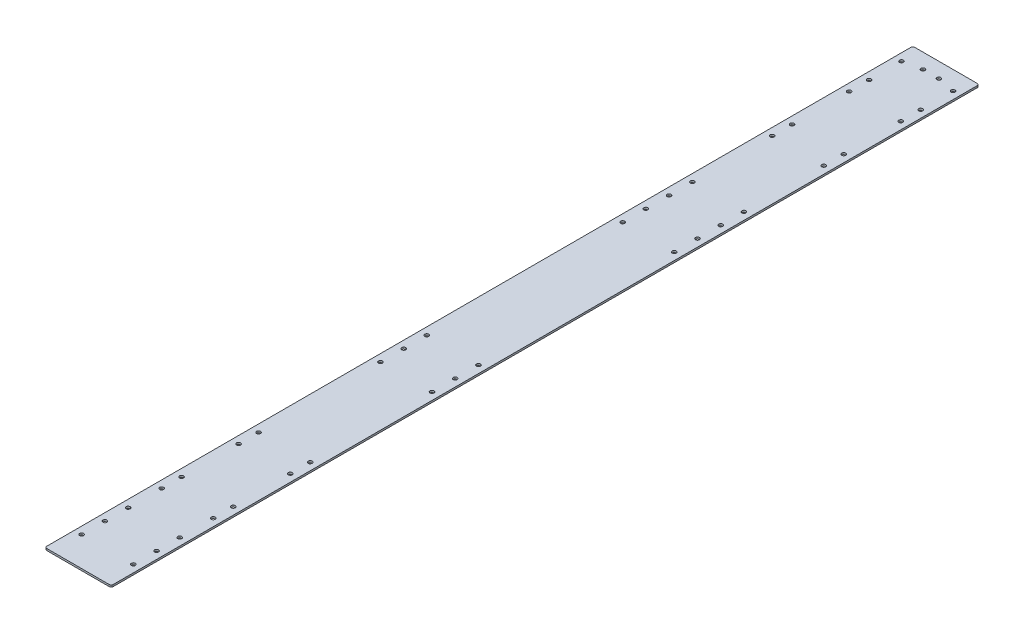
from build123d import *

# Parameters (mm, degrees)
BOSS_EXTRUDE1_DEPTH = 2.8
CUT_EXTRUDE1_REACH  = 4.8
SKETCH2_R           = 3
CUT_EXTRUDE2_REACH  = 4.8
SKETCH3_R           = 3
CUT_EXTRUDE3_REACH  = 4.8
SKETCH4_R           = 3
CUT_EXTRUDE4_REACH  = 4.8
SKETCH5_R           = 3


with BuildPart() as part:
    # Sketch1 → Boss-Extrude1 (new body)
    with BuildSketch(Plane(origin=(0, 0, 0), x_dir=(1, 0, 0), z_dir=(0, 1, 0))):
        with BuildLine():
            Line((3, 0), (97, 0))
            ThreePointArc((97, 0), (99.121320344, 0.878679656), (100, 3))
            Line((100, 3), (100, 1305))
            ThreePointArc((100, 1305), (99.121320344, 1307.121320344), (97, 1308))
            Line((97, 1308), (3, 1308))
            ThreePointArc((3, 1308), (0.878679656, 1307.121320344), (0, 1305))
            Line((0, 1305), (0, 3))
            ThreePointArc((0, 3), (0.878679656, 0.878679656), (3, 0))
        make_face()
    extrude(amount=BOSS_EXTRUDE1_DEPTH)

    # Sketch2 → Cut-Extrude1 (cut, up to next)
    with BuildSketch(Plane(origin=(0, 2.8, 0), x_dir=(1, 0, 0), z_dir=(0, 1, 0)), mode=Mode.PRIVATE) as cut_extrude1_sk1:
        with Locations((88.9, 1279.78)):
            Circle(SKETCH2_R)
    cut_extrude1_tool1 = extrude(cut_extrude1_sk1.sketch, amount=-CUT_EXTRUDE1_REACH, mode=Mode.PRIVATE) & part.part
    add(cut_extrude1_tool1.solids().sort_by_distance((88.9, 2.8, -1279.78))[0], mode=Mode.SUBTRACT)
    # Sketch2 → Cut-Extrude1 (cut, up to next)
    with BuildSketch(Plane(origin=(0, 2.8, 0), x_dir=(1, 0, 0), z_dir=(0, 1, 0)), mode=Mode.PRIVATE) as cut_extrude1_sk2:
        with Locations((88.9, 929.61)):
            Circle(SKETCH2_R)
    cut_extrude1_tool2 = extrude(cut_extrude1_sk2.sketch, amount=-CUT_EXTRUDE1_REACH, mode=Mode.PRIVATE) & part.part
    add(cut_extrude1_tool2.solids().sort_by_distance((88.9, 2.8, -929.61))[0], mode=Mode.SUBTRACT)
    # Sketch2 → Cut-Extrude1 (cut, up to next)
    with BuildSketch(Plane(origin=(0, 2.8, 0), x_dir=(1, 0, 0), z_dir=(0, 1, 0)), mode=Mode.PRIVATE) as cut_extrude1_sk3:
        with Locations((88.9, 529.56)):
            Circle(SKETCH2_R)
    cut_extrude1_tool3 = extrude(cut_extrude1_sk3.sketch, amount=-CUT_EXTRUDE1_REACH, mode=Mode.PRIVATE) & part.part
    add(cut_extrude1_tool3.solids().sort_by_distance((88.9, 2.8, -529.56))[0], mode=Mode.SUBTRACT)
    # Sketch2 → Cut-Extrude1 (cut, up to next)
    with BuildSketch(Plane(origin=(0, 2.8, 0), x_dir=(1, 0, 0), z_dir=(0, 1, 0)), mode=Mode.PRIVATE) as cut_extrude1_sk4:
        with Locations((88.9, 79.44)):
            Circle(SKETCH2_R)
    cut_extrude1_tool4 = extrude(cut_extrude1_sk4.sketch, amount=-CUT_EXTRUDE1_REACH, mode=Mode.PRIVATE) & part.part
    add(cut_extrude1_tool4.solids().sort_by_distance((88.9, 2.8, -79.44))[0], mode=Mode.SUBTRACT)
    # Sketch2 → Cut-Extrude1 (cut, up to next)
    with BuildSketch(Plane(origin=(0, 2.8, 0), x_dir=(1, 0, 0), z_dir=(0, 1, 0)), mode=Mode.PRIVATE) as cut_extrude1_sk5:
        with Locations((11.1, 79.44)):
            Circle(SKETCH2_R)
    cut_extrude1_tool5 = extrude(cut_extrude1_sk5.sketch, amount=-CUT_EXTRUDE1_REACH, mode=Mode.PRIVATE) & part.part
    add(cut_extrude1_tool5.solids().sort_by_distance((11.1, 2.8, -79.44))[0], mode=Mode.SUBTRACT)
    # Sketch2 → Cut-Extrude1 (cut, up to next)
    with BuildSketch(Plane(origin=(0, 2.8, 0), x_dir=(1, 0, 0), z_dir=(0, 1, 0)), mode=Mode.PRIVATE) as cut_extrude1_sk6:
        with Locations((11.1, 529.56)):
            Circle(SKETCH2_R)
    cut_extrude1_tool6 = extrude(cut_extrude1_sk6.sketch, amount=-CUT_EXTRUDE1_REACH, mode=Mode.PRIVATE) & part.part
    add(cut_extrude1_tool6.solids().sort_by_distance((11.1, 2.8, -529.56))[0], mode=Mode.SUBTRACT)
    # Sketch2 → Cut-Extrude1 (cut, up to next)
    with BuildSketch(Plane(origin=(0, 2.8, 0), x_dir=(1, 0, 0), z_dir=(0, 1, 0)), mode=Mode.PRIVATE) as cut_extrude1_sk7:
        with Locations((11.1, 929.61)):
            Circle(SKETCH2_R)
    cut_extrude1_tool7 = extrude(cut_extrude1_sk7.sketch, amount=-CUT_EXTRUDE1_REACH, mode=Mode.PRIVATE) & part.part
    add(cut_extrude1_tool7.solids().sort_by_distance((11.1, 2.8, -929.61))[0], mode=Mode.SUBTRACT)
    # Sketch2 → Cut-Extrude1 (cut, up to next)
    with BuildSketch(Plane(origin=(0, 2.8, 0), x_dir=(1, 0, 0), z_dir=(0, 1, 0)), mode=Mode.PRIVATE) as cut_extrude1_sk8:
        with Locations((11.1, 1279.78)):
            Circle(SKETCH2_R)
    cut_extrude1_tool8 = extrude(cut_extrude1_sk8.sketch, amount=-CUT_EXTRUDE1_REACH, mode=Mode.PRIVATE) & part.part
    add(cut_extrude1_tool8.solids().sort_by_distance((11.1, 2.8, -1279.78))[0], mode=Mode.SUBTRACT)

    # Sketch3 → Cut-Extrude2 (cut, up to next)
    with BuildSketch(Plane(origin=(0, 2.8, 0), x_dir=(1, 0, 0), z_dir=(0, 1, 0)), mode=Mode.PRIVATE) as cut_extrude2_sk1:
        with Locations((88.9, 1201)):
            Circle(SKETCH3_R)
    cut_extrude2_tool1 = extrude(cut_extrude2_sk1.sketch, amount=-CUT_EXTRUDE2_REACH, mode=Mode.PRIVATE) & part.part
    add(cut_extrude2_tool1.solids().sort_by_distance((88.9, 2.8, -1201))[0], mode=Mode.SUBTRACT)
    # Sketch3 → Cut-Extrude2 (cut, up to next)
    with BuildSketch(Plane(origin=(0, 2.8, 0), x_dir=(1, 0, 0), z_dir=(0, 1, 0)), mode=Mode.PRIVATE) as cut_extrude2_sk2:
        with Locations((88.9, 1115)):
            Circle(SKETCH3_R)
    cut_extrude2_tool2 = extrude(cut_extrude2_sk2.sketch, amount=-CUT_EXTRUDE2_REACH, mode=Mode.PRIVATE) & part.part
    add(cut_extrude2_tool2.solids().sort_by_distance((88.9, 2.8, -1115))[0], mode=Mode.SUBTRACT)
    # Sketch3 → Cut-Extrude2 (cut, up to next)
    with BuildSketch(Plane(origin=(0, 2.8, 0), x_dir=(1, 0, 0), z_dir=(0, 1, 0)), mode=Mode.PRIVATE) as cut_extrude2_sk3:
        with Locations((11.1, 1115)):
            Circle(SKETCH3_R)
    cut_extrude2_tool3 = extrude(cut_extrude2_sk3.sketch, amount=-CUT_EXTRUDE2_REACH, mode=Mode.PRIVATE) & part.part
    add(cut_extrude2_tool3.solids().sort_by_distance((11.1, 2.8, -1115))[0], mode=Mode.SUBTRACT)
    # Sketch3 → Cut-Extrude2 (cut, up to next)
    with BuildSketch(Plane(origin=(0, 2.8, 0), x_dir=(1, 0, 0), z_dir=(0, 1, 0)), mode=Mode.PRIVATE) as cut_extrude2_sk4:
        with Locations((11.1, 1201)):
            Circle(SKETCH3_R)
    cut_extrude2_tool4 = extrude(cut_extrude2_sk4.sketch, amount=-CUT_EXTRUDE2_REACH, mode=Mode.PRIVATE) & part.part
    add(cut_extrude2_tool4.solids().sort_by_distance((11.1, 2.8, -1201))[0], mode=Mode.SUBTRACT)
    # Sketch3 → Cut-Extrude2 (cut, up to next)
    with BuildSketch(Plane(origin=(0, 2.8, 0), x_dir=(1, 0, 0), z_dir=(0, 1, 0)), mode=Mode.PRIVATE) as cut_extrude2_sk5:
        with Locations((88.9, 281)):
            Circle(SKETCH3_R)
    cut_extrude2_tool5 = extrude(cut_extrude2_sk5.sketch, amount=-CUT_EXTRUDE2_REACH, mode=Mode.PRIVATE) & part.part
    add(cut_extrude2_tool5.solids().sort_by_distance((88.9, 2.8, -281))[0], mode=Mode.SUBTRACT)
    # Sketch3 → Cut-Extrude2 (cut, up to next)
    with BuildSketch(Plane(origin=(0, 2.8, 0), x_dir=(1, 0, 0), z_dir=(0, 1, 0)), mode=Mode.PRIVATE) as cut_extrude2_sk6:
        with Locations((88.9, 195)):
            Circle(SKETCH3_R)
    cut_extrude2_tool6 = extrude(cut_extrude2_sk6.sketch, amount=-CUT_EXTRUDE2_REACH, mode=Mode.PRIVATE) & part.part
    add(cut_extrude2_tool6.solids().sort_by_distance((88.9, 2.8, -195))[0], mode=Mode.SUBTRACT)
    # Sketch3 → Cut-Extrude2 (cut, up to next)
    with BuildSketch(Plane(origin=(0, 2.8, 0), x_dir=(1, 0, 0), z_dir=(0, 1, 0)), mode=Mode.PRIVATE) as cut_extrude2_sk7:
        with Locations((11.1, 195)):
            Circle(SKETCH3_R)
    cut_extrude2_tool7 = extrude(cut_extrude2_sk7.sketch, amount=-CUT_EXTRUDE2_REACH, mode=Mode.PRIVATE) & part.part
    add(cut_extrude2_tool7.solids().sort_by_distance((11.1, 2.8, -195))[0], mode=Mode.SUBTRACT)
    # Sketch3 → Cut-Extrude2 (cut, up to next)
    with BuildSketch(Plane(origin=(0, 2.8, 0), x_dir=(1, 0, 0), z_dir=(0, 1, 0)), mode=Mode.PRIVATE) as cut_extrude2_sk8:
        with Locations((11.1, 281)):
            Circle(SKETCH3_R)
    cut_extrude2_tool8 = extrude(cut_extrude2_sk8.sketch, amount=-CUT_EXTRUDE2_REACH, mode=Mode.PRIVATE) & part.part
    add(cut_extrude2_tool8.solids().sort_by_distance((11.1, 2.8, -281))[0], mode=Mode.SUBTRACT)

    # Sketch4 → Cut-Extrude3 (cut, up to next)
    with BuildSketch(Plane(origin=(0, 2.8, 0), x_dir=(1, 0, 0), z_dir=(0, 1, 0)), mode=Mode.PRIVATE) as cut_extrude3_sk1:
        with Locations((88.9, 1231)):
            Circle(SKETCH4_R)
    cut_extrude3_tool1 = extrude(cut_extrude3_sk1.sketch, amount=-CUT_EXTRUDE3_REACH, mode=Mode.PRIVATE) & part.part
    add(cut_extrude3_tool1.solids().sort_by_distance((88.9, 2.8, -1231))[0], mode=Mode.SUBTRACT)
    # Sketch4 → Cut-Extrude3 (cut, up to next)
    with BuildSketch(Plane(origin=(0, 2.8, 0), x_dir=(1, 0, 0), z_dir=(0, 1, 0)), mode=Mode.PRIVATE) as cut_extrude3_sk2:
        with Locations((88.9, 1085)):
            Circle(SKETCH4_R)
    cut_extrude3_tool2 = extrude(cut_extrude3_sk2.sketch, amount=-CUT_EXTRUDE3_REACH, mode=Mode.PRIVATE) & part.part
    add(cut_extrude3_tool2.solids().sort_by_distance((88.9, 2.8, -1085))[0], mode=Mode.SUBTRACT)
    # Sketch4 → Cut-Extrude3 (cut, up to next)
    with BuildSketch(Plane(origin=(0, 2.8, 0), x_dir=(1, 0, 0), z_dir=(0, 1, 0)), mode=Mode.PRIVATE) as cut_extrude3_sk3:
        with Locations((88.9, 964.61)):
            Circle(SKETCH4_R)
    cut_extrude3_tool3 = extrude(cut_extrude3_sk3.sketch, amount=-CUT_EXTRUDE3_REACH, mode=Mode.PRIVATE) & part.part
    add(cut_extrude3_tool3.solids().sort_by_distance((88.9, 2.8, -964.61))[0], mode=Mode.SUBTRACT)
    # Sketch4 → Cut-Extrude3 (cut, up to next)
    with BuildSketch(Plane(origin=(0, 2.8, 0), x_dir=(1, 0, 0), z_dir=(0, 1, 0)), mode=Mode.PRIVATE) as cut_extrude3_sk4:
        with Locations((88.9, 894.61)):
            Circle(SKETCH4_R)
    cut_extrude3_tool4 = extrude(cut_extrude3_sk4.sketch, amount=-CUT_EXTRUDE3_REACH, mode=Mode.PRIVATE) & part.part
    add(cut_extrude3_tool4.solids().sort_by_distance((88.9, 2.8, -894.61))[0], mode=Mode.SUBTRACT)
    # Sketch4 → Cut-Extrude3 (cut, up to next)
    with BuildSketch(Plane(origin=(0, 2.8, 0), x_dir=(1, 0, 0), z_dir=(0, 1, 0)), mode=Mode.PRIVATE) as cut_extrude3_sk5:
        with Locations((88.9, 564.56)):
            Circle(SKETCH4_R)
    cut_extrude3_tool5 = extrude(cut_extrude3_sk5.sketch, amount=-CUT_EXTRUDE3_REACH, mode=Mode.PRIVATE) & part.part
    add(cut_extrude3_tool5.solids().sort_by_distance((88.9, 2.8, -564.56))[0], mode=Mode.SUBTRACT)
    # Sketch4 → Cut-Extrude3 (cut, up to next)
    with BuildSketch(Plane(origin=(0, 2.8, 0), x_dir=(1, 0, 0), z_dir=(0, 1, 0)), mode=Mode.PRIVATE) as cut_extrude3_sk6:
        with Locations((88.9, 494.56)):
            Circle(SKETCH4_R)
    cut_extrude3_tool6 = extrude(cut_extrude3_sk6.sketch, amount=-CUT_EXTRUDE3_REACH, mode=Mode.PRIVATE) & part.part
    add(cut_extrude3_tool6.solids().sort_by_distance((88.9, 2.8, -494.56))[0], mode=Mode.SUBTRACT)
    # Sketch4 → Cut-Extrude3 (cut, up to next)
    with BuildSketch(Plane(origin=(0, 2.8, 0), x_dir=(1, 0, 0), z_dir=(0, 1, 0)), mode=Mode.PRIVATE) as cut_extrude3_sk7:
        with Locations((88.9, 114.44)):
            Circle(SKETCH4_R)
    cut_extrude3_tool7 = extrude(cut_extrude3_sk7.sketch, amount=-CUT_EXTRUDE3_REACH, mode=Mode.PRIVATE) & part.part
    add(cut_extrude3_tool7.solids().sort_by_distance((88.9, 2.8, -114.44))[0], mode=Mode.SUBTRACT)
    # Sketch4 → Cut-Extrude3 (cut, up to next)
    with BuildSketch(Plane(origin=(0, 2.8, 0), x_dir=(1, 0, 0), z_dir=(0, 1, 0)), mode=Mode.PRIVATE) as cut_extrude3_sk8:
        with Locations((88.9, 44.44)):
            Circle(SKETCH4_R)
    cut_extrude3_tool8 = extrude(cut_extrude3_sk8.sketch, amount=-CUT_EXTRUDE3_REACH, mode=Mode.PRIVATE) & part.part
    add(cut_extrude3_tool8.solids().sort_by_distance((88.9, 2.8, -44.44))[0], mode=Mode.SUBTRACT)
    # Sketch4 → Cut-Extrude3 (cut, up to next)
    with BuildSketch(Plane(origin=(0, 2.8, 0), x_dir=(1, 0, 0), z_dir=(0, 1, 0)), mode=Mode.PRIVATE) as cut_extrude3_sk9:
        with Locations((88.9, 311)):
            Circle(SKETCH4_R)
    cut_extrude3_tool9 = extrude(cut_extrude3_sk9.sketch, amount=-CUT_EXTRUDE3_REACH, mode=Mode.PRIVATE) & part.part
    add(cut_extrude3_tool9.solids().sort_by_distance((88.9, 2.8, -311))[0], mode=Mode.SUBTRACT)
    # Sketch4 → Cut-Extrude3 (cut, up to next)
    with BuildSketch(Plane(origin=(0, 2.8, 0), x_dir=(1, 0, 0), z_dir=(0, 1, 0)), mode=Mode.PRIVATE) as cut_extrude3_sk10:
        with Locations((88.9, 165)):
            Circle(SKETCH4_R)
    cut_extrude3_tool10 = extrude(cut_extrude3_sk10.sketch, amount=-CUT_EXTRUDE3_REACH, mode=Mode.PRIVATE) & part.part
    add(cut_extrude3_tool10.solids().sort_by_distance((88.9, 2.8, -165))[0], mode=Mode.SUBTRACT)
    # Sketch4 → Cut-Extrude3 (cut, up to next)
    with BuildSketch(Plane(origin=(0, 2.8, 0), x_dir=(1, 0, 0), z_dir=(0, 1, 0)), mode=Mode.PRIVATE) as cut_extrude3_sk11:
        with Locations((11.1, 165)):
            Circle(SKETCH4_R)
    cut_extrude3_tool11 = extrude(cut_extrude3_sk11.sketch, amount=-CUT_EXTRUDE3_REACH, mode=Mode.PRIVATE) & part.part
    add(cut_extrude3_tool11.solids().sort_by_distance((11.1, 2.8, -165))[0], mode=Mode.SUBTRACT)
    # Sketch4 → Cut-Extrude3 (cut, up to next)
    with BuildSketch(Plane(origin=(0, 2.8, 0), x_dir=(1, 0, 0), z_dir=(0, 1, 0)), mode=Mode.PRIVATE) as cut_extrude3_sk12:
        with Locations((11.1, 311)):
            Circle(SKETCH4_R)
    cut_extrude3_tool12 = extrude(cut_extrude3_sk12.sketch, amount=-CUT_EXTRUDE3_REACH, mode=Mode.PRIVATE) & part.part
    add(cut_extrude3_tool12.solids().sort_by_distance((11.1, 2.8, -311))[0], mode=Mode.SUBTRACT)
    # Sketch4 → Cut-Extrude3 (cut, up to next)
    with BuildSketch(Plane(origin=(0, 2.8, 0), x_dir=(1, 0, 0), z_dir=(0, 1, 0)), mode=Mode.PRIVATE) as cut_extrude3_sk13:
        with Locations((11.1, 44.44)):
            Circle(SKETCH4_R)
    cut_extrude3_tool13 = extrude(cut_extrude3_sk13.sketch, amount=-CUT_EXTRUDE3_REACH, mode=Mode.PRIVATE) & part.part
    add(cut_extrude3_tool13.solids().sort_by_distance((11.1, 2.8, -44.44))[0], mode=Mode.SUBTRACT)
    # Sketch4 → Cut-Extrude3 (cut, up to next)
    with BuildSketch(Plane(origin=(0, 2.8, 0), x_dir=(1, 0, 0), z_dir=(0, 1, 0)), mode=Mode.PRIVATE) as cut_extrude3_sk14:
        with Locations((11.1, 114.44)):
            Circle(SKETCH4_R)
    cut_extrude3_tool14 = extrude(cut_extrude3_sk14.sketch, amount=-CUT_EXTRUDE3_REACH, mode=Mode.PRIVATE) & part.part
    add(cut_extrude3_tool14.solids().sort_by_distance((11.1, 2.8, -114.44))[0], mode=Mode.SUBTRACT)
    # Sketch4 → Cut-Extrude3 (cut, up to next)
    with BuildSketch(Plane(origin=(0, 2.8, 0), x_dir=(1, 0, 0), z_dir=(0, 1, 0)), mode=Mode.PRIVATE) as cut_extrude3_sk15:
        with Locations((11.1, 494.56)):
            Circle(SKETCH4_R)
    cut_extrude3_tool15 = extrude(cut_extrude3_sk15.sketch, amount=-CUT_EXTRUDE3_REACH, mode=Mode.PRIVATE) & part.part
    add(cut_extrude3_tool15.solids().sort_by_distance((11.1, 2.8, -494.56))[0], mode=Mode.SUBTRACT)
    # Sketch4 → Cut-Extrude3 (cut, up to next)
    with BuildSketch(Plane(origin=(0, 2.8, 0), x_dir=(1, 0, 0), z_dir=(0, 1, 0)), mode=Mode.PRIVATE) as cut_extrude3_sk16:
        with Locations((11.1, 564.56)):
            Circle(SKETCH4_R)
    cut_extrude3_tool16 = extrude(cut_extrude3_sk16.sketch, amount=-CUT_EXTRUDE3_REACH, mode=Mode.PRIVATE) & part.part
    add(cut_extrude3_tool16.solids().sort_by_distance((11.1, 2.8, -564.56))[0], mode=Mode.SUBTRACT)
    # Sketch4 → Cut-Extrude3 (cut, up to next)
    with BuildSketch(Plane(origin=(0, 2.8, 0), x_dir=(1, 0, 0), z_dir=(0, 1, 0)), mode=Mode.PRIVATE) as cut_extrude3_sk17:
        with Locations((11.1, 894.61)):
            Circle(SKETCH4_R)
    cut_extrude3_tool17 = extrude(cut_extrude3_sk17.sketch, amount=-CUT_EXTRUDE3_REACH, mode=Mode.PRIVATE) & part.part
    add(cut_extrude3_tool17.solids().sort_by_distance((11.1, 2.8, -894.61))[0], mode=Mode.SUBTRACT)
    # Sketch4 → Cut-Extrude3 (cut, up to next)
    with BuildSketch(Plane(origin=(0, 2.8, 0), x_dir=(1, 0, 0), z_dir=(0, 1, 0)), mode=Mode.PRIVATE) as cut_extrude3_sk18:
        with Locations((11.1, 964.61)):
            Circle(SKETCH4_R)
    cut_extrude3_tool18 = extrude(cut_extrude3_sk18.sketch, amount=-CUT_EXTRUDE3_REACH, mode=Mode.PRIVATE) & part.part
    add(cut_extrude3_tool18.solids().sort_by_distance((11.1, 2.8, -964.61))[0], mode=Mode.SUBTRACT)
    # Sketch4 → Cut-Extrude3 (cut, up to next)
    with BuildSketch(Plane(origin=(0, 2.8, 0), x_dir=(1, 0, 0), z_dir=(0, 1, 0)), mode=Mode.PRIVATE) as cut_extrude3_sk19:
        with Locations((11.1, 1085)):
            Circle(SKETCH4_R)
    cut_extrude3_tool19 = extrude(cut_extrude3_sk19.sketch, amount=-CUT_EXTRUDE3_REACH, mode=Mode.PRIVATE) & part.part
    add(cut_extrude3_tool19.solids().sort_by_distance((11.1, 2.8, -1085))[0], mode=Mode.SUBTRACT)
    # Sketch4 → Cut-Extrude3 (cut, up to next)
    with BuildSketch(Plane(origin=(0, 2.8, 0), x_dir=(1, 0, 0), z_dir=(0, 1, 0)), mode=Mode.PRIVATE) as cut_extrude3_sk20:
        with Locations((11.1, 1231)):
            Circle(SKETCH4_R)
    cut_extrude3_tool20 = extrude(cut_extrude3_sk20.sketch, amount=-CUT_EXTRUDE3_REACH, mode=Mode.PRIVATE) & part.part
    add(cut_extrude3_tool20.solids().sort_by_distance((11.1, 2.8, -1231))[0], mode=Mode.SUBTRACT)
    # Sketch4 → Cut-Extrude3 (cut, up to next)
    with BuildSketch(Plane(origin=(0, 2.8, 0), x_dir=(1, 0, 0), z_dir=(0, 1, 0)), mode=Mode.PRIVATE) as cut_extrude3_sk21:
        with Locations((88.9, 859.61)):
            Circle(SKETCH4_R)
    cut_extrude3_tool21 = extrude(cut_extrude3_sk21.sketch, amount=-CUT_EXTRUDE3_REACH, mode=Mode.PRIVATE) & part.part
    add(cut_extrude3_tool21.solids().sort_by_distance((88.9, 2.8, -859.61))[0], mode=Mode.SUBTRACT)
    # Sketch4 → Cut-Extrude3 (cut, up to next)
    with BuildSketch(Plane(origin=(0, 2.8, 0), x_dir=(1, 0, 0), z_dir=(0, 1, 0)), mode=Mode.PRIVATE) as cut_extrude3_sk22:
        with Locations((11.1, 859.61)):
            Circle(SKETCH4_R)
    cut_extrude3_tool22 = extrude(cut_extrude3_sk22.sketch, amount=-CUT_EXTRUDE3_REACH, mode=Mode.PRIVATE) & part.part
    add(cut_extrude3_tool22.solids().sort_by_distance((11.1, 2.8, -859.61))[0], mode=Mode.SUBTRACT)

    # Sketch5 → Cut-Extrude4 (cut, up to next)
    with BuildSketch(Plane(origin=(0, 2.8, 0), x_dir=(1, 0, 0), z_dir=(0, 1, 0)), mode=Mode.PRIVATE) as cut_extrude4_sk1:
        with Locations((37.99, 1285.31)):
            Circle(SKETCH5_R)
    cut_extrude4_tool1 = extrude(cut_extrude4_sk1.sketch, amount=-CUT_EXTRUDE4_REACH, mode=Mode.PRIVATE) & part.part
    add(cut_extrude4_tool1.solids().sort_by_distance((37.99, 2.8, -1285.31))[0], mode=Mode.SUBTRACT)
    # Sketch5 → Cut-Extrude4 (cut, up to next)
    with BuildSketch(Plane(origin=(0, 2.8, 0), x_dir=(1, 0, 0), z_dir=(0, 1, 0)), mode=Mode.PRIVATE) as cut_extrude4_sk2:
        with Locations((62.01, 1285.31)):
            Circle(SKETCH5_R)
    cut_extrude4_tool2 = extrude(cut_extrude4_sk2.sketch, amount=-CUT_EXTRUDE4_REACH, mode=Mode.PRIVATE) & part.part
    add(cut_extrude4_tool2.solids().sort_by_distance((62.01, 2.8, -1285.31))[0], mode=Mode.SUBTRACT)


solid = part.part
